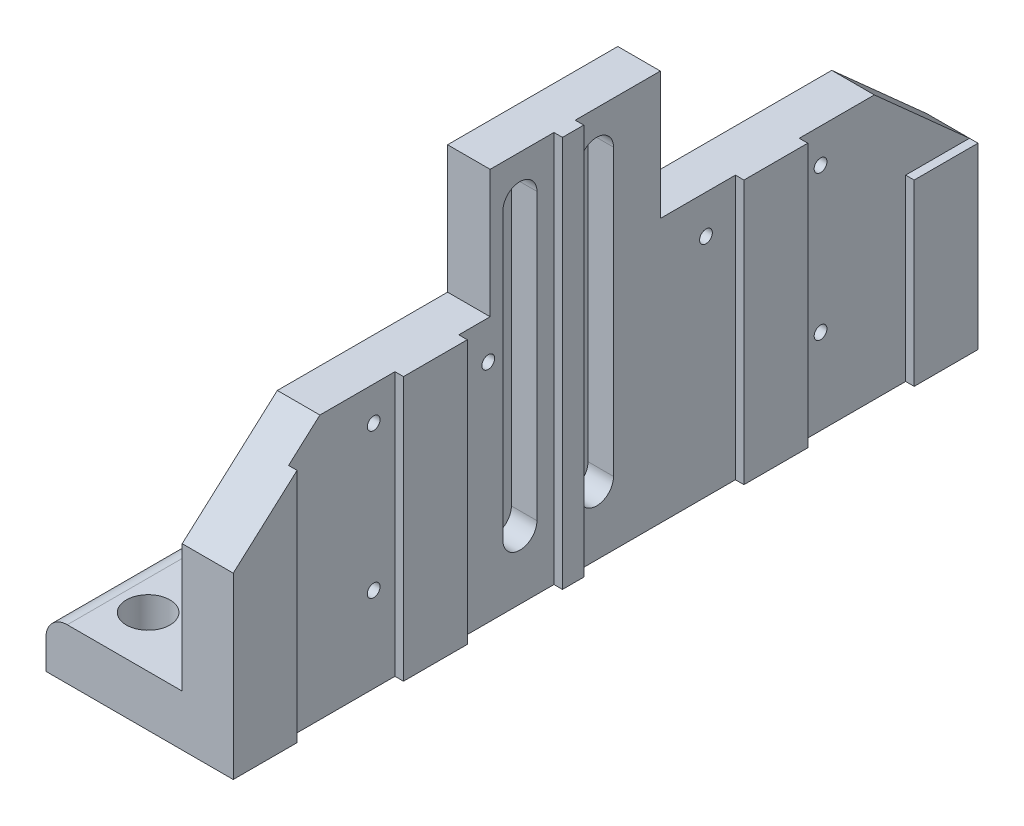
from build123d import *

# Parameters (mm, degrees)
SKETCH1_W               = 4.2
SKETCH1_H               = 17.5
BOSS_EXTRUDE1_DEPTH     = 1.2
SKETCH2_W               = 1
SKETCH2_H               = 17.5
BOSS_EXTRUDE2_DEPTH     = 5
CUT_EXTRUDE1_DEPTH      = 1.3
CUT_EXTRUDE1_DEPTH_BACK = 5
SKETCH4_W               = 4
SKETCH4_H               = 3
BOSS_EXTRUDE3_DEPTH     = 1
SKETCH5_R               = 0.5125
CUT_EXTRUDE2_DEPTH      = 20.694923204
SKETCH6_R               = 0.5
CUT_EXTRUDE3_DEPTH      = 0.75
CUT_EXTRUDE5_DEPTH      = 1.3
CUT_EXTRUDE5_DEPTH_BACK = 21.212125074
SKETCH11_R              = 0.15
CUT_EXTRUDE7_DEPTH      = 0.2
CUT_EXTRUDE6_DEPTH      = 1.3
CUT_EXTRUDE6_DEPTH_BACK = 1.3
SKETCH14_W              = 1.5
SKETCH14_H              = 6.2
SKETCH14_H_2            = 4.2
SKETCH14_W_2            = 0.5
SKETCH14_H_3            = 9.2
BOSS_EXTRUDE5_DEPTH     = 0.2
FILLET1_R               = 0.5
CUT_EXTRUDE8_DEPTH      = 0.6


with BuildPart() as part:
    # Sketch1 → Boss-Extrude1 (new body)
    with BuildSketch(Plane(origin=(0, 0, 0), x_dir=(1, 0, 0), z_dir=(0, 1, 0))):
        with Locations((2.1, 8.75)):
            Rectangle(SKETCH1_W, SKETCH1_H)
    extrude(amount=BOSS_EXTRUDE1_DEPTH)

    # Sketch2 → Boss-Extrude2 (add)
    with BuildSketch(Plane(origin=(0, 1.2, 0), x_dir=(1, 0, 0), z_dir=(0, 1, 0))):
        with Locations((3.7, 8.75)):
            Rectangle(SKETCH2_W, SKETCH2_H)
    extrude(amount=BOSS_EXTRUDE2_DEPTH)

    # Sketch3 → Cut-Extrude1 (cut, two sides: drawn at the far end of the back side and taken through both)
    with BuildSketch(Plane(origin=(4.2, 0, 0), x_dir=(0, 0, -1), z_dir=(1, 0, 0)).offset(-CUT_EXTRUDE1_DEPTH_BACK)):
        Polygon((0, 4.2), (0, 6.2), (2.236067977, 6.2), align=None)
        Polygon((17.5, 6.2), (15.263932023, 6.2), (17.5, 4.2), align=None)
    extrude(amount=CUT_EXTRUDE1_DEPTH + CUT_EXTRUDE1_DEPTH_BACK, mode=Mode.SUBTRACT)

    # Sketch4 → Boss-Extrude3 (add)
    with BuildSketch(Plane(origin=(4.2, 0, 0), x_dir=(0, 0, -1), z_dir=(1, 0, 0))):
        with Locations((8.236067977, 7.7)):
            Rectangle(SKETCH4_W, SKETCH4_H)
    extrude(amount=-BOSS_EXTRUDE3_DEPTH)

    # Sketch5 → Cut-Extrude2 (cut, through all)
    with BuildSketch(Plane(origin=(0, 1.2, 0), x_dir=(1, 0, 0), z_dir=(0, 1, 0))):
        with Locations((1.2, 16.3)):
            Circle(SKETCH5_R)
        with Locations((1.2, 1.2)):
            Circle(SKETCH5_R)
    extrude(amount=-CUT_EXTRUDE2_DEPTH, mode=Mode.SUBTRACT)

    # Sketch6 → Cut-Extrude3 (cut)
    with BuildSketch(Plane(origin=(0, 1.2, 0), x_dir=(1, 0, 0), z_dir=(0, 1, 0))):
        with Locations((1.4, 8.8)):
            Circle(SKETCH6_R)
    extrude(amount=-CUT_EXTRUDE3_DEPTH, mode=Mode.SUBTRACT)

    # Sketch11 → Cut-Extrude5 (cut, two sides: drawn at the far end of the back side and taken through both)
    with BuildSketch(Plane(origin=(4.2, 0, 0), x_dir=(0, 0, -1), z_dir=(1, 0, 0)).offset(-CUT_EXTRUDE5_DEPTH_BACK)):
        with Locations((3.5, 5.40229833)):
            Circle(SKETCH11_R)
        with Locations((6.191844332, 5.3)):
            Circle(SKETCH11_R)
        with Locations((3.5, 2)):
            Circle(SKETCH11_R)
        with Locations((11.308155668, 5.3)):
            Circle(SKETCH11_R)
        with Locations((14, 5.4)):
            Circle(SKETCH11_R)
        with Locations((14, 2)):
            Circle(SKETCH11_R)
    extrude(amount=CUT_EXTRUDE5_DEPTH + CUT_EXTRUDE5_DEPTH_BACK, mode=Mode.SUBTRACT)

    # Sketch15 → Cut-Extrude7 (cut)
    with BuildSketch(Plane.ZY.offset(-3.2)):
        Polygon((-14, 5.75), (-14.303108891, 5.575), (-14.303108891, 5.225), (-14, 5.05), (-13.696891109, 5.225), (-13.696891109, 5.575), align=None)
        Polygon((-11.308155668, 5.65), (-11.611264559, 5.475), (-11.611264559, 5.125), (-11.308155668, 4.95), (-11.005046777, 5.125), (-11.005046777, 5.475), align=None)
        Polygon((-14, 2.35), (-14.303108891, 2.175), (-14.303108891, 1.825), (-14, 1.65), (-13.696891109, 1.825), (-13.696891109, 2.175), align=None)
        Polygon((-6.191844332, 5.65), (-6.494953223, 5.475), (-6.494953223, 5.125), (-6.191844332, 4.95), (-5.888735441, 5.125), (-5.888735441, 5.475), align=None)
        Polygon((-3.5, 5.75229833), (-3.803108891, 5.57729833), (-3.803108891, 5.22729833), (-3.5, 5.05229833), (-3.196891109, 5.22729833), (-3.196891109, 5.57729833), align=None)
        Polygon((-3.5, 2.35), (-3.803108891, 2.175), (-3.803108891, 1.825), (-3.5, 1.65), (-3.196891109, 1.825), (-3.196891109, 2.175), align=None)
    extrude(amount=-CUT_EXTRUDE7_DEPTH, mode=Mode.SUBTRACT)

    # Sketch12 → Cut-Extrude6 (cut, two sides: drawn at the far end of the back side and taken through both)
    with BuildSketch(Plane(origin=(4.2, 0, 0), x_dir=(0, 0, -1), z_dir=(1, 0, 0)).offset(-CUT_EXTRUDE6_DEPTH_BACK)):
        with BuildLine():
            Line((8.886067977, 8.2), (8.886067977, 1.5))
            ThreePointArc((8.886067977, 1.5), (8.736067977, 1.35), (8.586067977, 1.5))
            Line((8.586067977, 1.5), (8.586067977, 8.2))
            ThreePointArc((8.586067977, 8.2), (8.736067977, 8.35), (8.886067977, 8.2))
        make_face()
        with BuildLine():
            Line((7.086067977, 8.2), (7.086067977, 1.5))
            ThreePointArc((7.086067977, 1.5), (6.936067977, 1.35), (6.786067977, 1.5))
            Line((6.786067977, 1.5), (6.786067977, 8.2))
            ThreePointArc((6.786067977, 8.2), (6.936067977, 8.35), (7.086067977, 8.2))
        make_face()
    extrude(amount=CUT_EXTRUDE6_DEPTH + CUT_EXTRUDE6_DEPTH_BACK, mode=Mode.SUBTRACT)

    # Sketch14 → Boss-Extrude5 (add)
    with BuildSketch(Plane(origin=(4.2, 0, 0), x_dir=(0, 0, -1), z_dir=(1, 0, 0))):
        with Locations((4.75, 3.1)):
            Rectangle(SKETCH14_W, SKETCH14_H)
        Polygon((1.5, 5.541640786), (0, 4.2), (0, 0), (1.5, 0), align=None)
        with Locations((12.75, 3.1)):
            Rectangle(SKETCH14_W, SKETCH14_H)
        with Locations((16.75, 2.1)):
            Rectangle(SKETCH14_W, SKETCH14_H_2)
        with Locations((7.986067977, 4.6)):
            Rectangle(SKETCH14_W_2, SKETCH14_H_3)
    extrude(amount=BOSS_EXTRUDE5_DEPTH)

    # Fillet1
    fillet1_edges = [part.edges().sort_by_distance(p)[0] for p in [
        (0, 1.2, -8.75),
    ]]
    fillet(fillet1_edges, radius=FILLET1_R)

    # Sketch16 → Cut-Extrude8 (cut)
    with BuildSketch(Plane(origin=(4.2, 0, 0), x_dir=(0, 0, -1), z_dir=(1, 0, 0))):
        with BuildLine():
            Line((8.336067977, 1.5), (8.336067977, 8.2))
            ThreePointArc((8.336067977, 8.2), (8.736067977, 8.6), (9.136067977, 8.2))
            Line((9.136067977, 8.2), (9.136067977, 1.5))
            ThreePointArc((9.136067977, 1.5), (8.736067977, 1.1), (8.336067977, 1.5))
        make_face()
        with BuildLine():
            Line((6.536067977, 1.5), (6.536067977, 8.2))
            ThreePointArc((6.536067977, 8.2), (6.936067977, 8.6), (7.336067977, 8.2))
            Line((7.336067977, 8.2), (7.336067977, 1.5))
            ThreePointArc((7.336067977, 1.5), (6.936067977, 1.1), (6.536067977, 1.5))
        make_face()
    extrude(amount=-CUT_EXTRUDE8_DEPTH, mode=Mode.SUBTRACT)


solid = part.part
